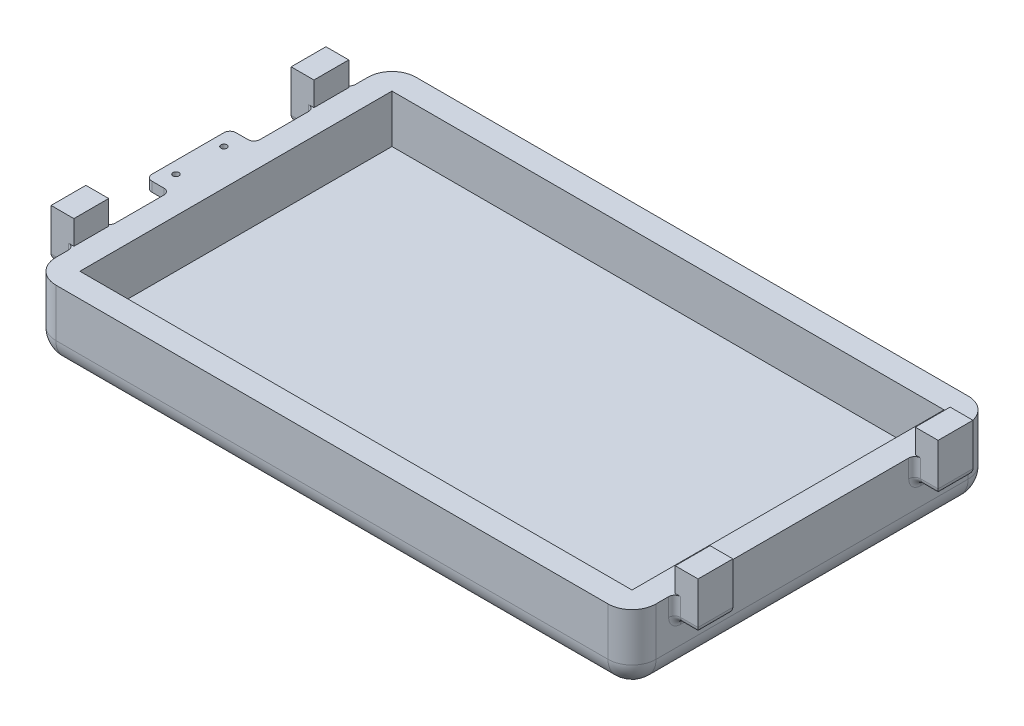
from build123d import *

# Parameters (mm, degrees)
SKETCH1_W                = 250
SKETCH1_H                = 150
BOSS_EXTRUDE1_DEPTH      = 30
SKETCH2_W                = 230
SKETCH2_H                = 130
CUT_EXTRUDE1_DEPTH       = 20
FILLET1_R                = 10
SKETCH3_W                = 9.75
SKETCH3_H                = 14.5
BOSS_EXTRUDE2_DEPTH      = 10
BOSS_EXTRUDE2_DEPTH_BACK = 10
FILLET3_R                = 2.5
SKETCH4_W                = 250.5
SKETCH4_H                = 135.53043316
CUT_EXTRUDE3_DEPTH       = 36
SKETCH5_W                = 10
SKETCH5_H                = 35
SKETCH5_R                = 1.25
BOSS_EXTRUDE5_DEPTH      = 4
FILLET4_R                = 2.5


with BuildPart() as part:
    # Sketch1 → Boss-Extrude1 (new body)
    with BuildSketch(Plane(origin=(0, 0, 0), x_dir=(1, 0, 0), z_dir=(0, 1, 0))):
        Rectangle(SKETCH1_W, SKETCH1_H)
    extrude(amount=BOSS_EXTRUDE1_DEPTH)

    # Sketch2 → Cut-Extrude1 (cut)
    with BuildSketch(Plane(origin=(0, 30, 0), x_dir=(1, 0, 0), z_dir=(0, 1, 0))):
        Rectangle(SKETCH2_W, SKETCH2_H)
    extrude(amount=-CUT_EXTRUDE1_DEPTH, mode=Mode.SUBTRACT)

    # Fillet1
    fillet1_edges = [part.edges().sort_by_distance(p)[0] for p in [
        (0, 0, 75),
        (-125, 0, 0),
        (0, 0, -75),
        (125, 0, 0),
        (125, 15, 75),
        (-125, 15, 75),
        (-125, 15, -75),
        (125, 15, -75),
    ]]
    fillet(fillet1_edges, radius=FILLET1_R)

    # Sketch3 → Boss-Extrude2 (add, two sides)
    with BuildSketch(Plane(origin=(0, 30, 0), x_dir=(1, 0, 0), z_dir=(0, 1, 0))) as boss_extrude2_sk:
        with Locations((-129.875, 50)):
            Rectangle(SKETCH3_W, SKETCH3_H)
        with Locations((-129.875, -50)):
            Rectangle(SKETCH3_W, SKETCH3_H)
        with Locations((129.875, -50)):
            Rectangle(SKETCH3_W, SKETCH3_H)
        with Locations((129.875, 50)):
            Rectangle(SKETCH3_W, SKETCH3_H)
    extrude(amount=BOSS_EXTRUDE2_DEPTH)
    extrude(boss_extrude2_sk.sketch, amount=-BOSS_EXTRUDE2_DEPTH_BACK)

    # Fillet3
    fillet3_edges = [part.edges().sort_by_distance(p)[0] for p in [
        (125, 20, -50),
        (125, 25, -42.75),
        (125, 25, -57.25),
        (129.875, 20, -57.25),
        (134.75, 20, -50),
        (129.875, 20, -42.75),
        (-125, 20, -50),
        (-125, 25, -57.25),
        (-125, 25, -42.75),
        (-129.875, 20, -42.75),
        (-134.75, 20, -50),
        (-129.875, 20, -57.25),
        (-125, 20, 50),
        (-125, 25, 42.75),
        (-125, 25, 57.25),
        (-129.875, 20, 57.25),
        (-134.75, 20, 50),
        (-129.875, 20, 42.75),
        (125, 20, 50),
        (125, 25, 57.25),
        (125, 25, 42.75),
        (129.875, 20, 42.75),
        (134.75, 20, 50),
        (129.875, 20, 57.25),
    ]]
    fillet(fillet3_edges, radius=FILLET3_R)

    # Sketch4 → Cut-Extrude3 (cut)
    with BuildSketch(Plane(origin=(0, 30, 0), x_dir=(1, 0, 0), z_dir=(0, 1, 0))):
        Rectangle(SKETCH4_W, SKETCH4_H)
    extrude(amount=CUT_EXTRUDE3_DEPTH, mode=Mode.SUBTRACT)

    # Sketch5 → Boss-Extrude5 (add)
    with BuildSketch(Plane(origin=(0, 30, 0), x_dir=(1, 0, 0), z_dir=(0, 1, 0))):
        with Locations((-130, 0)):
            Rectangle(SKETCH5_W, SKETCH5_H)
        with Locations((-130, 10)):
            Circle(SKETCH5_R, mode=Mode.SUBTRACT)
        with Locations((-130, -10)):
            Circle(SKETCH5_R, mode=Mode.SUBTRACT)
    extrude(amount=-BOSS_EXTRUDE5_DEPTH)

    # Fillet4
    fillet4_edges = [part.edges().sort_by_distance(p)[0] for p in [
        (-125, 28, -17.5),
        (-125, 28, 17.5),
        (-135, 28, 17.5),
        (-135, 28, -17.5),
    ]]
    fillet(fillet4_edges, radius=FILLET4_R)


solid = part.part
